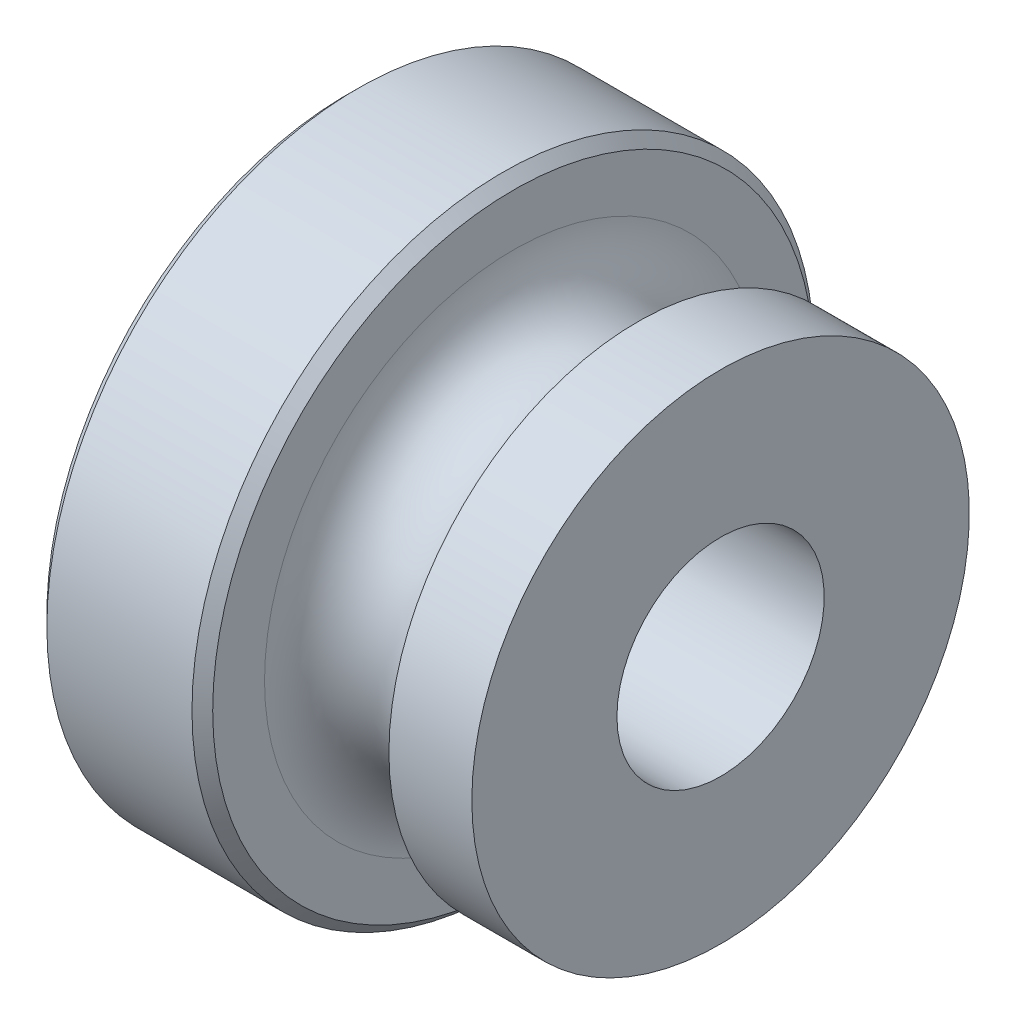
from build123d import *

# Parameters (mm, degrees)
CHAMFER1_SIZE = 0.5


with BuildPart() as part:
    # Sketch1 → Revolve1 (revolve)
    with BuildSketch(Plane.XY):
        with BuildLine():
            Line((18, 12), (18, 5))
            Line((18, 5), (3, 5))
            Line((3, 5), (3, 7))
            ThreePointArc((3, 7), (2.121320344, 9.121320344), (0, 10))
            Line((0, 10), (0, 15))
            Line((0, 15), (8, 15))
            Line((8, 15), (8, 12))
            ThreePointArc((8, 12), (11, 9), (14, 12))
            Line((14, 12), (18, 12))
        make_face()
    revolve(axis=Axis((0, 0, 0), (1, 0, 0)))

    # Chamfer1
    chamfer1_edges = [part.edges().sort_by_distance(p)[0] for p in [
        (0, -15, 0),
        (8, -15, 0),
    ]]
    chamfer(chamfer1_edges, length=CHAMFER1_SIZE)


solid = part.part
